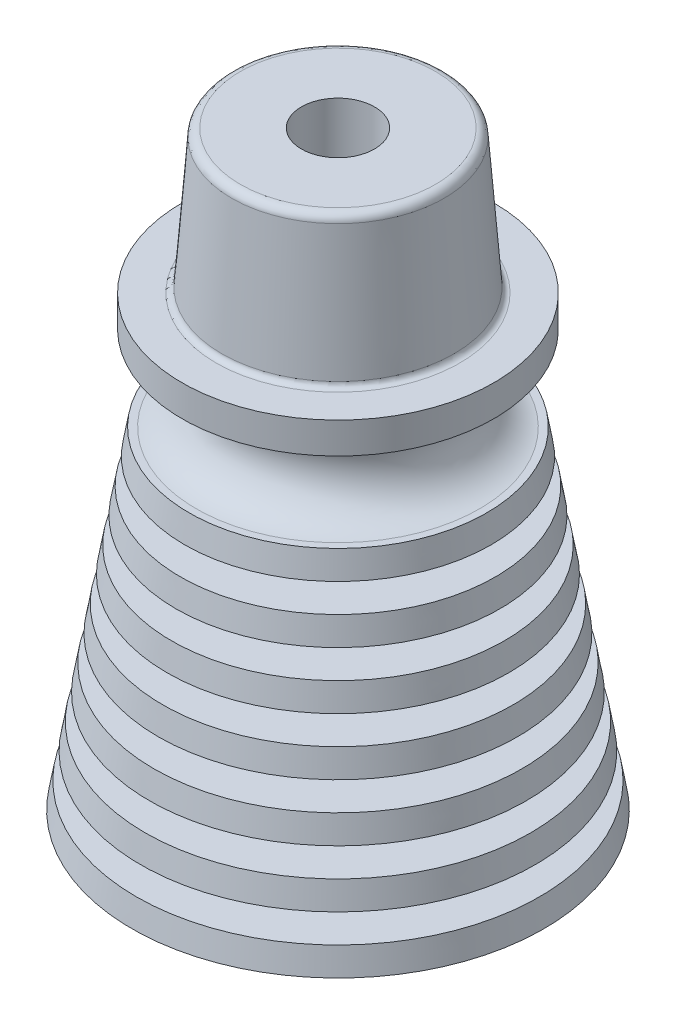
from build123d import *

# Parameters (mm, degrees)
SKETCH5_R          = 1.6383
CUT_EXTRUDE1_DEPTH = 27.4668
FILLET1_R          = 0.381
FILLET2_R          = 0.254


with BuildPart() as part:
    # Sketch1 → Revolve1 (revolve)
    with BuildSketch(Plane.XY, mode=Mode.PRIVATE) as revolve1_sk:
        Polygon((4.571997254, 14.859), (6.235697254, 0), (4.191, 0), (2.5273, 14.859), align=None)
    revolve(revolve1_sk.sketch.rotate(Axis((0, 0, 0), (0, 1, 0)), 90), axis=Axis((0, 0, 0), (0, 1, 0)))  # turned: the seam where the file's is

    # Sketch2 → Revolve2 (revolve)
    with BuildSketch(Plane.XY, mode=Mode.PRIVATE) as revolve2_sk:
        Polygon((6.235697254, 0), (9.2329, 0), (9.035561538, 1.143), (6.107720331, 1.143), align=None)
        Polygon((4.571997254, 14.859), (4.699974177, 13.716), (6.864838462, 13.716), (6.6675, 14.859), align=None)
        Polygon((5.979743408, 2.286), (8.838223077, 2.286), (8.640884615, 3.429), (5.851766485, 3.429), align=None)
        Polygon((5.723789562, 4.572), (8.443546154, 4.572), (8.246207692, 5.715), (5.595812639, 5.715), align=None)
        Polygon((5.467835716, 6.858), (8.048869231, 6.858), (7.851530769, 8.001), (5.339858793, 8.001), align=None)
        Polygon((5.21188187, 9.144), (7.654192308, 9.144), (7.456853846, 10.287), (5.083904947, 10.287), align=None)
        Polygon((4.955928023, 11.43), (7.259515385, 11.43), (7.062176923, 12.573), (4.8279511, 12.573), align=None)
    revolve(revolve2_sk.sketch.rotate(Axis((0, 0, 0), (0, 1, 0)), 90), axis=Axis((0, 0, 0), (0, 1, 0)))  # turned: the seam where the file's is

    # Sketch3 → Revolve3 (revolve)
    with BuildSketch(Plane.XY, mode=Mode.PRIVATE) as revolve3_sk:
        with BuildLine():
            Line((6.35, 14.859), (0, 14.859))
            Line((0, 14.859), (0, 20.066))
            Line((0, 20.066), (6.985, 20.066))
            Line((6.985, 20.066), (6.985, 18.669))
            Line((6.985, 18.669), (6.35, 18.669))
            ThreePointArc((6.35, 18.669), (4.6863, 16.764), (6.35, 14.859))
        make_face()
    revolve(revolve3_sk.sketch.rotate(Axis((0, 0, 0), (0, 1, 0)), 90), axis=Axis((0, 0, 0), (0, 1, 0)))  # turned: the seam where the file's is

    # Sketch4 → Revolve4 (revolve)
    with BuildSketch(Plane.XY, mode=Mode.PRIVATE) as revolve4_sk:
        Polygon((5.2197, 20.066), (0, 20.066), (0, 26.4668), (4.733451381, 26.4668), align=None)
    revolve(revolve4_sk.sketch.rotate(Axis((0, 0, 0), (0, 1, 0)), 90), axis=Axis((0, 0, 0), (0, 1, 0)))  # turned: the seam where the file's is

    # Sketch5 → Cut-Extrude1 (cut, through all)
    with BuildSketch(Plane(origin=(0, 26.4668, 0), x_dir=(1, 0, 0), z_dir=(0, 1, 0))):
        with Locations(Location((0, 0, 0), (0, 0, 270))):  # turned: the seam where the file's is
            Circle(SKETCH5_R)
    extrude(amount=-CUT_EXTRUDE1_DEPTH, mode=Mode.SUBTRACT)

    # Fillet1
    fillet1_edges = [part.edges().sort_by_distance(p)[0] for p in [
        (0, 26.4668, 4.733451381),
    ]]
    fillet(fillet1_edges, radius=FILLET1_R)

    # Fillet2
    fillet2_edges = [part.edges().sort_by_distance(p)[0] for p in [
        (0, 20.066, 5.2197),
    ]]
    fillet(fillet2_edges, radius=FILLET2_R)


solid = part.part
